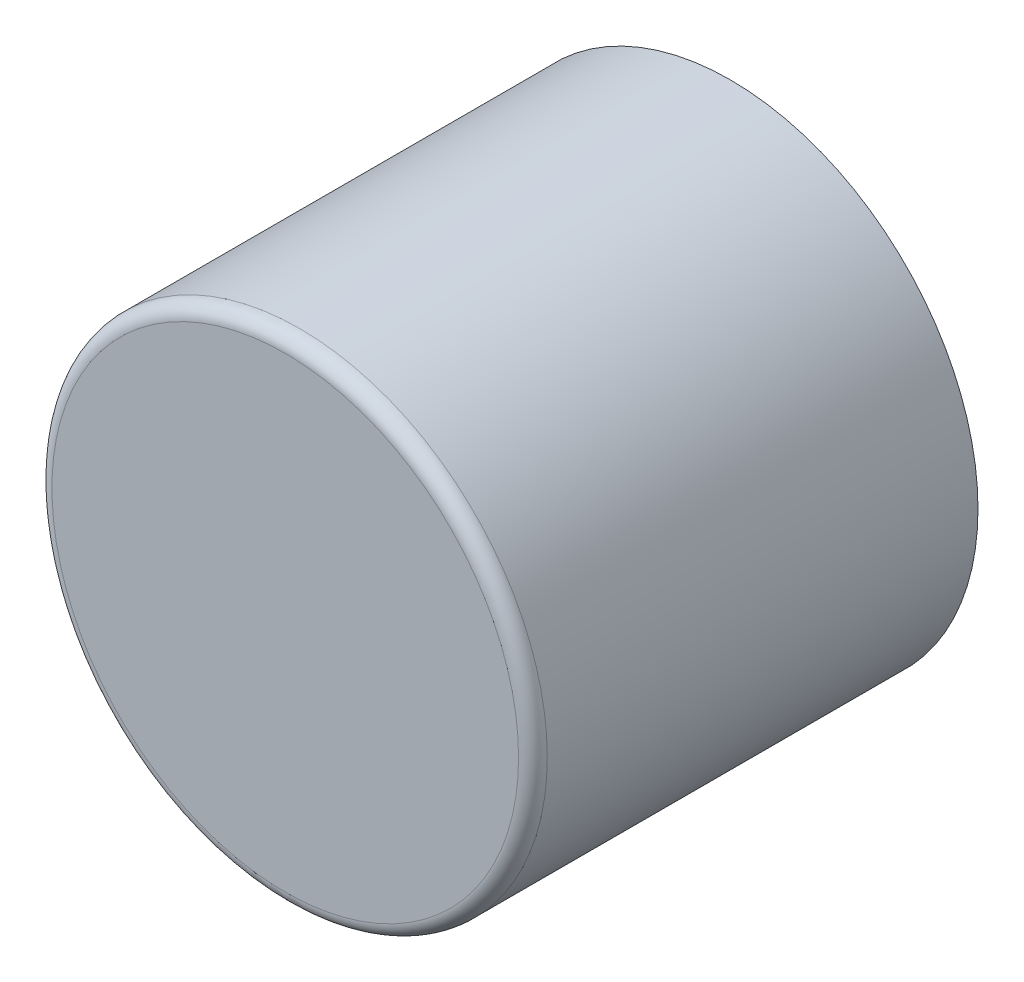
from build123d import *

# Parameters (mm, degrees)
SKETCH1_R           = 17.25
BOSS_EXTRUDE1_DEPTH = 31
FILLET1_R           = 1


with BuildPart() as part:
    # Sketch1 → Boss-Extrude1 (new body)
    with BuildSketch(Plane.XY):
        Circle(SKETCH1_R)
    extrude(amount=BOSS_EXTRUDE1_DEPTH)

    # Fillet1
    fillet1_edges = [part.edges().sort_by_distance(p)[0] for p in [
        (-17.25, 0, 31),
    ]]
    fillet(fillet1_edges, radius=FILLET1_R)


solid = part.part
